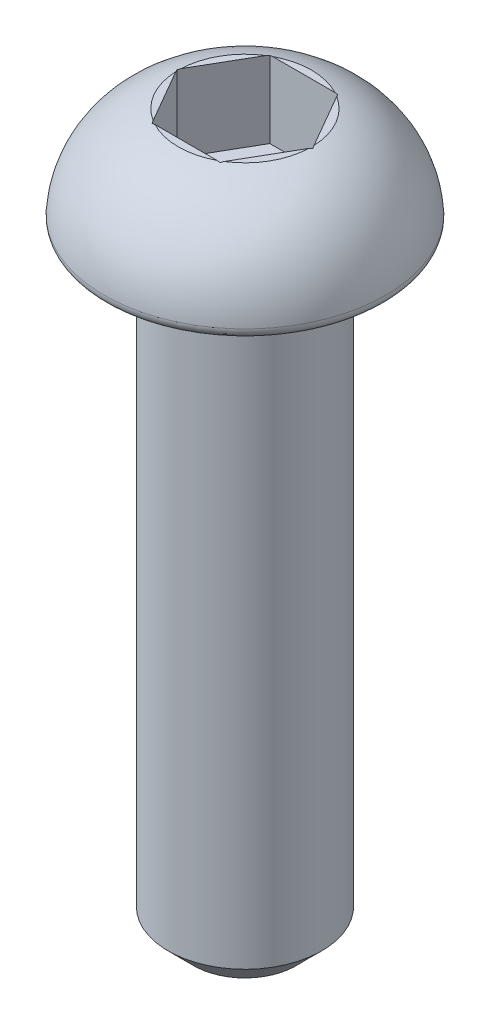
from build123d import *

# Parameters (mm, degrees)
FILLET_1_R          = 0.2
CUT_EXTRUDE_1_DEPTH = 1.5
SKETCH_3_R          = 1.5
EXTRUDE_1_DEPTH     = 12
CHAMFER_1_SIZE      = 0.5


with BuildPart() as part:
    # 草图1 → 旋转1 (revolve)
    with BuildSketch(Plane.XY):
        with BuildLine():
            Line((0, 0), (0, 2))
            Line((0, 2), (1.3, 2))
            ThreePointArc((1.3, 2), (2.370691821, 1.250626571), (2.75, 0))
            Line((2.75, 0), (0, 0))
        make_face()
    revolve(axis=Axis((0, 0, 0), (0, 1, 0)))

    # 圆角1
    fillet_1_edges = [part.edges().sort_by_distance(p)[0] for p in [
        (-2.75, 0, 0),
    ]]
    fillet(fillet_1_edges, radius=FILLET_1_R)

    # 草图2 → 切除-拉伸1 (cut)
    with BuildSketch(Plane(origin=(0, 2, 0), x_dir=(1, 0, 0), z_dir=(0, 1, 0))):
        Polygon((1.327905619, 0), (0.66395281, 1.15), (-0.66395281, 1.15), (-1.327905619, 0), (-0.66395281, -1.15), (0.66395281, -1.15), align=None)
    extrude(amount=-CUT_EXTRUDE_1_DEPTH, mode=Mode.SUBTRACT)

    # 草图3 → 凸台-拉伸1 (add)
    with BuildSketch(Plane.XZ):
        Circle(SKETCH_3_R)
    extrude(amount=EXTRUDE_1_DEPTH)

    # 倒角1
    chamfer_1_edges = [part.edges().sort_by_distance(p)[0] for p in [
        (-1.5, -12, 0),
    ]]
    chamfer(chamfer_1_edges, length=CHAMFER_1_SIZE)


solid = part.part
